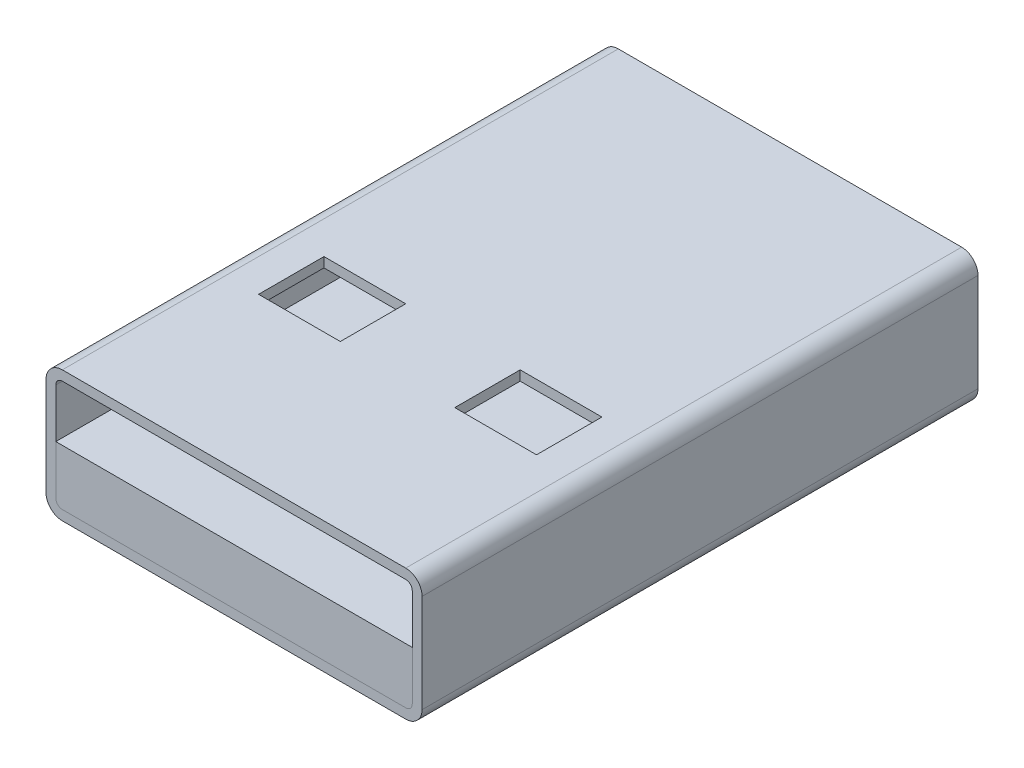
from build123d import *

# Parameters (mm, degrees)
SKETCH_1_W          = 11.5
SKETCH_1_H          = 4
EXTRUDE_1_DEPTH     = 17
FILLET_1_R          = 0.5
CUT_EXTRUDE_1_DEPTH = 18
SKETCH_4_W          = 2.5
SKETCH_4_H          = 2
CUT_EXTRUDE_2_DEPTH = 5
EXTRUDE_2_DEPTH     = 17


with BuildPart() as part:
    # Эскиз1 → Вытянуть1 (new body)
    with BuildSketch(Plane.XY):
        with Locations((5.75, 2)):
            Rectangle(SKETCH_1_W, SKETCH_1_H)
    extrude(amount=EXTRUDE_1_DEPTH)

    # Скругление1
    fillet_1_edges = [part.edges().sort_by_distance(p)[0] for p in [
        (0, 4, 8.5),
        (11.5, 4, 8.5),
        (11.5, 0, 8.5),
        (0, 0, 8.5),
    ]]
    fillet(fillet_1_edges, radius=FILLET_1_R)

    # Эскиз2 → Вырез-Вытянуть1 (cut, through all)
    with BuildSketch(Plane.XY.offset(17)):
        with BuildLine():
            Line((11.2, 0.5), (11.2, 3.5))
            ThreePointArc((11.2, 3.5), (11.141421356, 3.641421356), (11, 3.7))
            Line((11, 3.7), (0.5, 3.7))
            ThreePointArc((0.5, 3.7), (0.358578644, 3.641421356), (0.3, 3.5))
            Line((0.3, 3.5), (0.3, 0.5))
            ThreePointArc((0.3, 0.5), (0.358578644, 0.358578644), (0.5, 0.3))
            Line((0.5, 0.3), (11, 0.3))
            ThreePointArc((11, 0.3), (11.141421356, 0.358578644), (11.2, 0.5))
        make_face()
    extrude(amount=-CUT_EXTRUDE_1_DEPTH, mode=Mode.SUBTRACT)

    # Эскиз4 → Вырез-Вытянуть2 (cut, through all)
    with BuildSketch(Plane(origin=(0, 4, 0), x_dir=(1, 0, 0), z_dir=(0, 1, 0))):
        with Locations((2.75, -11)):
            Rectangle(SKETCH_4_W, SKETCH_4_H)
        with Locations((8.75, -11)):
            Rectangle(SKETCH_4_W, SKETCH_4_H)
    extrude(amount=-CUT_EXTRUDE_2_DEPTH, mode=Mode.SUBTRACT)


with BuildPart() as body_2:
    # Эскиз3 → Вытянуть2 (new body, through all)
    with BuildSketch(Plane.XY.offset(17)):
        with BuildLine():
            Line((11.2, 0.5), (11.2, 2))
            Line((11.2, 2), (0.3, 2))
            Line((0.3, 2), (0.3, 0.5))
            ThreePointArc((0.3, 0.5), (0.358578644, 0.358578644), (0.5, 0.3))
            Line((0.5, 0.3), (11, 0.3))
            ThreePointArc((11, 0.3), (11.141421356, 0.358578644), (11.2, 0.5))
        make_face()
    extrude(amount=-EXTRUDE_2_DEPTH)


solid = Compound([part.part, body_2.part])
